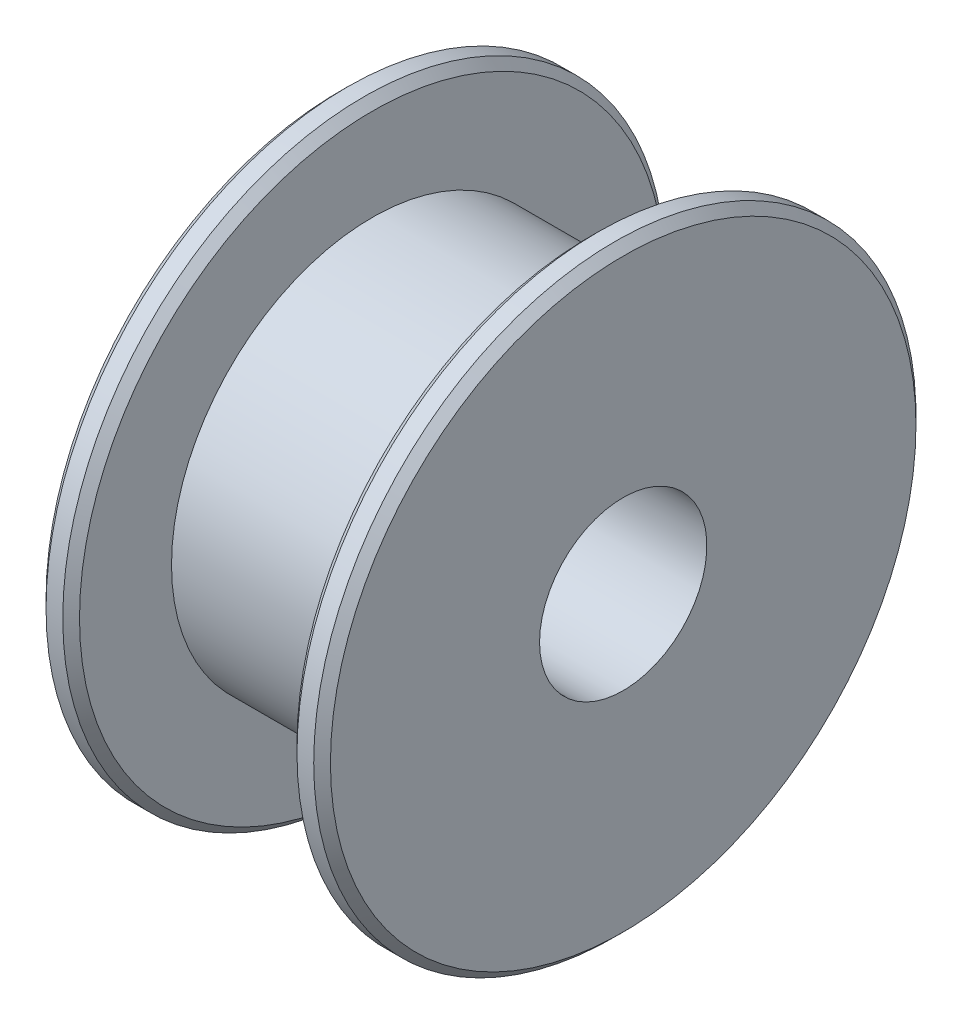
from build123d import *

# Parameters (mm, degrees)
SMUSSO1_SIZE = 0.25


with BuildPart() as part:
    # Schizzo1 → Rivoluzione1 (revolve)
    with BuildSketch(Plane.XY):
        Polygon((0, 2.5), (0, 9), (1, 9), (1, 6), (7.5, 6), (7.5, 9), (8.5, 9), (8.5, 2.5), align=None)
    revolve(axis=Axis((0, 0, 0), (1, 0, 0)))

    # Smusso1
    smusso1_edges = [part.edges().sort_by_distance(p)[0] for p in [
        (8.5, -9, 0),
        (7.5, -9, 0),
        (1, -9, 0),
        (0, -9, 0),
    ]]
    chamfer(smusso1_edges, length=SMUSSO1_SIZE)


solid = part.part
